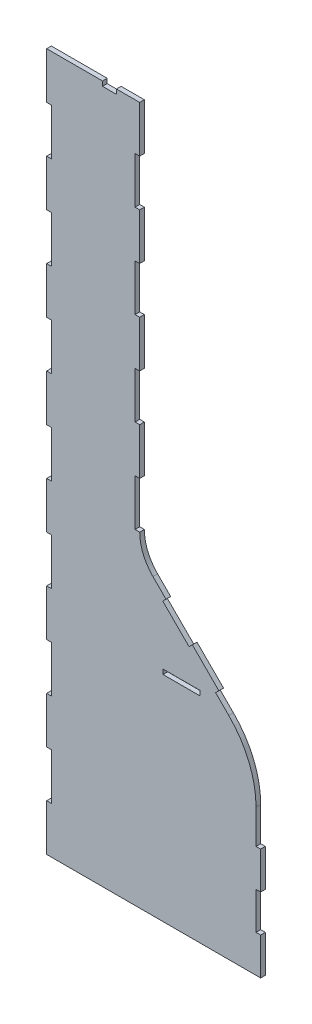
from build123d import *

# Parameters (mm, degrees)
ESQUISSE1_W             = 40
ESQUISSE1_H             = 5.1
BOSS_EXTRU_1_DEPTH      = 5
ENL_V_MAT_EXTRU_1_REACH = 7
BOSS_EXTRU_2_DEPTH      = 5


with BuildPart() as part:
    # Esquisse1 → Boss.-Extru.1 (new body)
    with BuildSketch(Plane.XY):
        Polygon((100, 330), (128.284271247, 301.715728753), (124.748737342, 298.180194847), (153.033008589, 269.895923599), (156.568542495, 273.431457505), (199.901875828, 230.098124172), (196.366341922, 226.562590266), (211.415404008, 211.51352818), (214.950937914, 215.049062086), (230, 200), (230, 160), (225, 160), (225, 120), (230, 120), (230, 80), (225, 80), (225, 40), (230, 40), (230, 0), (0, 0), (0, 50), (5, 50), (5, 100), (0, 100), (0, 150), (5, 150), (5, 200), (0, 200), (0, 250), (5, 250), (5, 300), (0, 300), (0, 350), (5, 350), (5, 400), (0, 400), (0, 450), (5, 450), (5, 500), (0, 500), (0, 550), (5, 550), (5, 600), (0, 600), (0, 650), (5, 650), (5, 700), (0, 700), (0, 750), (60, 750), (60, 745), (75, 745), (75, 750), (100, 750), (100, 700), (95, 700), (95, 650), (100, 650), (100, 600), (95, 600), (95, 550), (100, 550), (100, 500), (95, 500), (95, 450), (100, 450), (100, 400), (95, 400), (95, 350), (100, 350), align=None)
        with Locations((145, 232.55)):
            Rectangle(ESQUISSE1_W, ESQUISSE1_H, mode=Mode.SUBTRACT)
    extrude(amount=BOSS_EXTRU_1_DEPTH)

    # Esquisse3 → Enlèv. mat.-Extru.1 (cut, up to next)
    with BuildSketch(Plane.XY.offset(5), mode=Mode.PRIVATE) as enl_v_mat_extru_1_sk1:
        with BuildLine():
            Line((225, 156.507575951), (230, 156.507575951))
            Line((230, 156.507575951), (230, 200))
            Line((230, 200), (185.104076401, 244.895923599))
            Line((185.104076401, 244.895923599), (181.568542495, 241.360389693))
            Line((181.568542495, 241.360389693), (195.710678119, 227.218254069))
            ThreePointArc((195.710678119, 227.218254069), (217.387953251, 194.775919187), (225, 156.507575951))
        make_face()
    enl_v_mat_extru_1_tool1 = extrude(enl_v_mat_extru_1_sk1.sketch, amount=-ENL_V_MAT_EXTRU_1_REACH, mode=Mode.PRIVATE) & part.part
    add(enl_v_mat_extru_1_tool1.solids().sort_by_distance((215.711514, 201.173028, 5))[0], mode=Mode.SUBTRACT)

    # Esquisse4 → Boss.-Extru.2 (add)
    with BuildSketch(Plane.XY.offset(5)):
        with BuildLine():
            Line((100, 350), (100, 330))
            Line((100, 330), (114.142135624, 315.857864376))
            ThreePointArc((114.142135624, 315.857864376), (103.6754213, 331.52240935), (100, 350))
        make_face()
    extrude(amount=-BOSS_EXTRU_2_DEPTH)


solid = part.part
